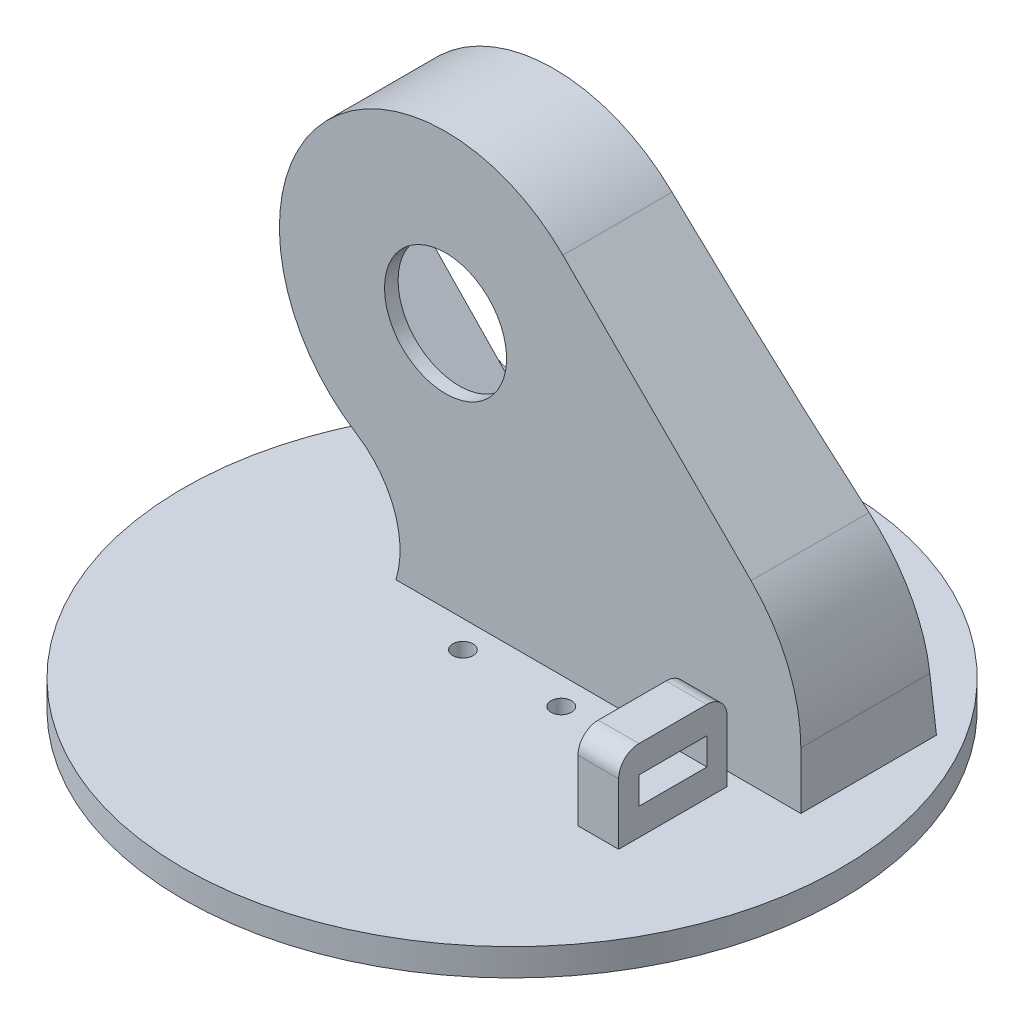
from build123d import *

# Parameters (mm, degrees)
IZIM2_R                     = 48.5
IZIM2_R_2                   = 1.5
Y_KSEKLIK_EKSTR_ZYON1_DEPTH = 4
Y_KSEKLIK_EKSTR_ZYON2_DEPTH = 20
KES_EKSTR_ZYON2_DEPTH       = 9
KES_EKSTR_ZYON4_DEPTH       = 18
IZIM8_R                     = 8.999373408
KES_EKSTR_ZYON6_DEPTH       = 20
IZIM10_R                    = 1.3
KES_EKSTR_ZYON7_DEPTH       = 13
Y_KSEKLIK_EKSTR_ZYON3_DEPTH = 12
RADYUS1_R                   = 3
RADYUS2_R                   = 3
IZIM11_W                    = 10
IZIM11_H                    = 4
KES_EKSTR_ZYON8_DEPTH       = 6
IZIM12_R                    = 4.00063253
KES_EKSTR_ZYON9_DEPTH       = 2
KES_EKSTR_ZYON10_DEPTH      = 40
KES_EKSTR_ZYON10_DEPTH_BACK = 40


with BuildPart() as part:
    # Çizim2 → Yükseklik-Ekstrüzyon1 (new body)
    with BuildSketch(Plane(origin=(0, 0, 0), x_dir=(1, 0, 0), z_dir=(0, 1, 0))):
        with Locations(Location((0, -4, 0), (0, 0, 270))):
            Circle(IZIM2_R)
        with Locations(Location((7.25, -4, 0), (0, 0, 270))):
            Circle(IZIM2_R_2, mode=Mode.SUBTRACT)
        with Locations(Location((-7.25, -4, 0), (0, 0, 270))):
            Circle(IZIM2_R_2, mode=Mode.SUBTRACT)
    extrude(amount=-Y_KSEKLIK_EKSTR_ZYON1_DEPTH)

    # Çizim3 → Yükseklik-Ekstrüzyon2 (add)
    with BuildSketch(Plane.XY):
        with BuildLine():
            Line((31.238930549, 26.071347433), (3.495879159, 53.755241116))
            ThreePointArc((3.495879159, 53.755241116), (-32.936073069, 51.72385839), (-26.943926702, 15.730694583))
            ThreePointArc((-26.943926702, 15.730694583), (-21.379626349, 8.847295043), (-21.118861947, 0))
            Line((-21.118861947, 0), (-8.860527496, 0))
            Line((-8.860527496, 0), (38.580138623, 0))
            Line((38.580138623, 0), (38.580138623, 8.374820438))
            ThreePointArc((38.580138623, 8.374820438), (36.672018128, 17.954230697), (31.238930549, 26.071347433))
        make_face()
    extrude(amount=-Y_KSEKLIK_EKSTR_ZYON2_DEPTH)

    # Çizim5 → Kes-Ekstrüzyon2 (cut)
    with BuildSketch(Plane(origin=(0, 0, -20), x_dir=(-1, 0, 0), z_dir=(0, 0, -1))):
        with BuildLine():
            Line((-29.580138623, 0), (-29.580138623, 8.355768388))
            ThreePointArc((-29.580138623, 8.355768388), (-29.424047841, 10.115726146), (-28.960648361, 11.820741267))
            ThreePointArc((-28.960648361, 11.820741267), (-23.965436041, 23.095860189), (-17.588526551, 33.651213249))
            ThreePointArc((-17.588526551, 33.651213249), (-17.177321901, 34.202292772), (-16.7292201, 34.72381236))
            Line((-16.7292201, 34.72381236), (0, 52.891150841))
            ThreePointArc((0, 52.891150841), (32.164197471, 47.609241385), (22.142551812, 16.593103896))
            ThreePointArc((22.142551812, 16.593103896), (14.125970591, 9.960582753), (11.118861947, 0))
            Line((11.118861947, 0), (-29.580138623, 0))
        make_face()
    extrude(amount=-KES_EKSTR_ZYON2_DEPTH, mode=Mode.SUBTRACT)

    # Çizim7 → Kes-Ekstrüzyon4 (cut)
    with BuildSketch(Plane(origin=(0, 0, -20), x_dir=(-1, 0, 0), z_dir=(0, 0, -1))):
        Polygon((28.483058649, 36.490937082), (0, 7), (-15.105114115, 21.588883698), (13.377944534, 51.079820781), align=None)
    extrude(amount=-KES_EKSTR_ZYON4_DEPTH, mode=Mode.SUBTRACT)

    # Çizim8 → Kes-Ekstrüzyon6 (cut)
    with BuildSketch(Plane(origin=(0, 0, -20), x_dir=(-1, 0, 0), z_dir=(0, 0, -1))):
        with Locations((13.809736929, 36.412644661)):
            Circle(IZIM8_R)
    extrude(amount=-KES_EKSTR_ZYON6_DEPTH, mode=Mode.SUBTRACT)

    # Çizim10 → Kes-Ekstrüzyon7 (cut)
    with BuildSketch(Plane(origin=(0, 0, -20), x_dir=(-1, 0, 0), z_dir=(0, 0, -1))):
        with Locations((-13.580138623, 15.2501239)):
            Circle(IZIM10_R)
        with Locations((-6.318582157, 8.374820438)):
            Circle(IZIM10_R)
        with Locations((19.765881259, 49.77609902)):
            Circle(IZIM10_R)
        with Locations((27.027437725, 42.900795558)):
            Circle(IZIM10_R)
    extrude(amount=-KES_EKSTR_ZYON7_DEPTH, mode=Mode.SUBTRACT)

    # 3B Çizim1 → Yükseklik-Ekstrüzyon3 (add)
    with BuildSketch(Plane(origin=(29.714278279, 0, 2), x_dir=(-0.35112344158839165, 0, 0.9363291775690447), z_dir=(0, 1, 0))):
        Polygon((0, 0), (14.981266841, 5.617975065), (17.088007491, 0), (2.10674065, -5.617975065), align=None)
    extrude(amount=Y_KSEKLIK_EKSTR_ZYON3_DEPTH)

    # Radyus1
    radyus1_edges = [part.edges().sort_by_distance(p)[0] for p in [
        (26.714278279, 12, 18),
    ]]
    fillet(radyus1_edges, radius=RADYUS1_R)

    # Radyus2
    radyus2_edges = [part.edges().sort_by_distance(p)[0] for p in [
        (26.714278279, 12, 2),
    ]]
    fillet(radyus2_edges, radius=RADYUS2_R)

    # Çizim11 → Kes-Ekstrüzyon8 (cut)
    with BuildSketch(Plane(origin=(29.714278279, 0, 0), x_dir=(0, 0, -1), z_dir=(1, 0, 0))):
        with Locations((-9.980022365, 6)):
            Rectangle(IZIM11_W, IZIM11_H)
    extrude(amount=-KES_EKSTR_ZYON8_DEPTH, mode=Mode.SUBTRACT)

    # Çizim12 → Kes-Ekstrüzyon9 (cut)
    with BuildSketch(Plane(origin=(0, -4, 0), x_dir=(-1, 0, 0), z_dir=(0, -1, 0))):
        with Locations(Location((0.071138185, -4, 0), (0, 0, 90))):
            Circle(IZIM12_R)
    extrude(amount=-KES_EKSTR_ZYON9_DEPTH, mode=Mode.SUBTRACT)

    # Çizim13 → Kes-Ekstrüzyon10 (cut, two sides)
    with BuildSketch(Plane(origin=(0, 0, 0), x_dir=(0, 0, -1), z_dir=(1, 0, 0))) as kes_ekstr_zyon10_sk:
        with BuildLine():
            Line((16, 60.912644661), (25.8774704, 60.912644661))
            Line((25.8774704, 60.912644661), (25.8774704, 0))
            Line((25.8774704, 0), (20, 0))
            add(Edge.make_bspline(
                [(16, 60.912644661), (16.195964828, 30.341679785), (20, 0)],
                knots=[0, 0, 0, 1, 1, 1], degree=2))
        make_face()
    extrude(amount=KES_EKSTR_ZYON10_DEPTH, mode=Mode.SUBTRACT)
    extrude(kes_ekstr_zyon10_sk.sketch, amount=-KES_EKSTR_ZYON10_DEPTH_BACK, mode=Mode.SUBTRACT)


solid = part.part
